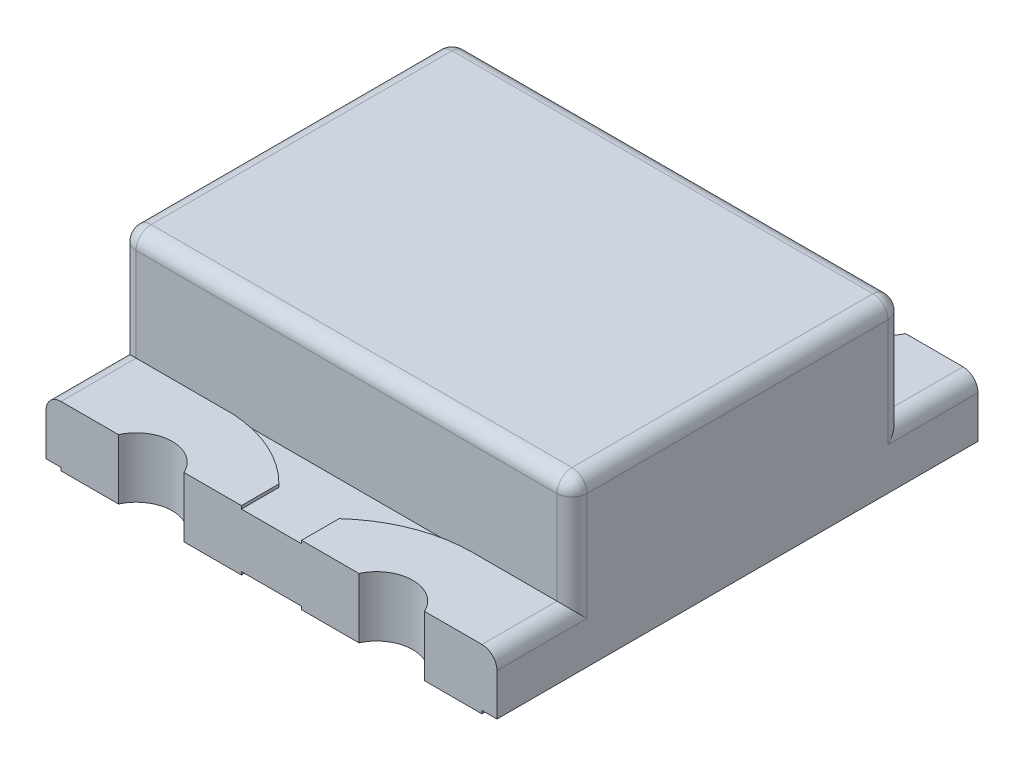
from build123d import *

# Parameters (mm, degrees)
SKETCH1_W           = 1.5
SKETCH1_H           = 1.6
BOSS_EXTRUDE1_DEPTH = 0.18
SKETCH2_W           = 1.5
SKETCH2_H           = 1.10096055
BOSS_EXTRUDE2_DEPTH = 0.55
FILLET1_R           = 0.05
BOSS_EXTRUDE4_DEPTH = 0.19
FILLET2_R           = 0.05
BOSS_EXTRUDE5_DEPTH = 0.01
CUT_EXTRUDE1_START  = -1.19
SKETCH4_R           = 0.12
CUT_EXTRUDE1_DEPTH  = 2.56


with BuildPart() as part:
    # Sketch1 → Boss-Extrude1 (new body)
    with BuildSketch(Plane(origin=(0, 0, 0), x_dir=(1, 0, 0), z_dir=(0, 1, 0))):
        with Locations((0.75, 0.8)):
            Rectangle(SKETCH1_W, SKETCH1_H)
    extrude(amount=BOSS_EXTRUDE1_DEPTH)

    # Sketch2 → Boss-Extrude2 (add)
    with BuildSketch(Plane(origin=(0, 0, 0), x_dir=(1, 0, 0), z_dir=(0, 1, 0))):
        with Locations((0.75, 0.8)):
            Rectangle(SKETCH2_W, SKETCH2_H)
    extrude(amount=BOSS_EXTRUDE2_DEPTH)

    # Fillet1
    fillet1_edges = [part.edges().sort_by_distance(p)[0] for p in [
        (0.75, 0.55, -1.350480275),
        (0.75, 0.55, -0.249519725),
    ]]
    fillet(fillet1_edges, radius=FILLET1_R)

    # Sketch3 → Boss-Extrude4 (add)
    with BuildSketch(Plane(origin=(0, 0, 0), x_dir=(1, 0, 0), z_dir=(0, 1, 0))):
        with BuildLine():
            Line((0.85, 1.6), (0.85, 1.475240137))
            ThreePointArc((0.85, 1.475240137), (1.000632183, 1.381944491), (1.175, 1.350480275))
            Line((1.175, 1.350480275), (1.5, 1.350480275))
            Line((1.5, 1.350480275), (1.5, 1.6))
            Line((1.5, 1.6), (0.85, 1.6))
        make_face()
        with BuildLine():
            Line((0.65, 1.475240137), (0.65, 1.6))
            Line((0.65, 1.6), (0, 1.6))
            Line((0, 1.6), (0, 1.350480275))
            Line((0, 1.350480275), (0.325, 1.350480275))
            ThreePointArc((0.325, 1.350480275), (0.500954095, 1.377812229), (0.65, 1.475240137))
        make_face()
    boss_extrude4 = extrude(amount=BOSS_EXTRUDE4_DEPTH)

    # Mirror1: Boss-Extrude4 across plane
    add(boss_extrude4.mirror(Plane.XY.offset(-0.8)))

    # Fillet2
    fillet2_edges = [part.edges().sort_by_distance(p)[0] for p in [
        (0, 0.19, -0.124759863),
        (1.5, 0.19, -0.124759863),
        (1.5, 0.55, -0.8),
        (0, 0.55, -0.8),
        (0, 0.345, -0.249519725),
        (0, 0.345, -1.350480275),
        (0, 0.535355339, -0.264164386),
        (0, 0.535355339, -1.335835614),
        (1.5, 0.345, -1.350480275),
        (1.5, 0.345, -0.249519725),
        (1.5, 0.535355339, -0.264164386),
        (1.5, 0.535355339, -1.335835614),
        (0, 0.19, -1.475240137),
        (1.5, 0.19, -1.475240137),
    ]]
    fillet(fillet2_edges, radius=FILLET2_R)

    # Sketch6 → Boss-Extrude5 (add)
    with BuildSketch(Plane(origin=(0, 0, 0), x_dir=(1, 0, 0), z_dir=(0, 1, 0))):
        Polygon((1.146090256, 0), (0.85, 0), (0.85, 0.4), (1.454870294, 0.4), (1.45, 0), align=None)
        Polygon((0.35, 0), (0.65, 0), (0.65, 0.4), (0.35, 0.4), (0.05, 0.4), (0.05, 0), align=None)
    boss_extrude5 = extrude(amount=-BOSS_EXTRUDE5_DEPTH)

    # Mirror3: Boss-Extrude5 across plane
    add(boss_extrude5.mirror(Plane.XY.offset(-0.8)))

    # Sketch4 → Cut-Extrude1 (cut)
    with BuildSketch(Plane(origin=(0, 0.18, 0), x_dir=(1, 0, 0), z_dir=(0, 1, 0)).offset(CUT_EXTRUDE1_START)):
        with Locations((0.35, 1.65)):
            Circle(SKETCH4_R)
        with Locations((1.15, 1.65)):
            Circle(SKETCH4_R)
    cut_extrude1 = extrude(amount=CUT_EXTRUDE1_DEPTH, mode=Mode.SUBTRACT)

    # Mirror2: Cut-Extrude1 across plane
    add(cut_extrude1.mirror(Plane.XY.offset(-0.8)), mode=Mode.SUBTRACT)


solid = part.part
